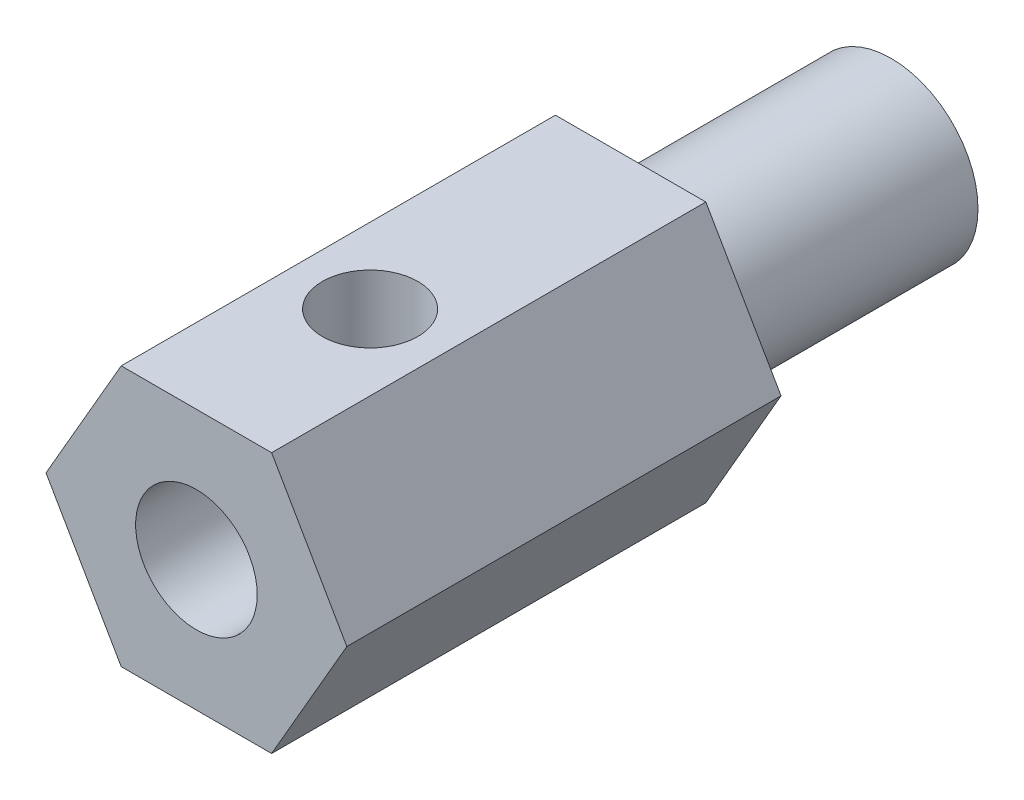
from build123d import *

# Parameters (mm, degrees)
BOSS_EXTRUDE1_DEPTH = 25.4
CUT_EXTRUDE1_DEPTH  = 8.89
SKETCH2_3_R         = 1.778
CUT_EXTRUDE2_DEPTH  = 2.54
SKETCH6_R           = 1.524
CUT_EXTRUDE3_DEPTH  = 16.51
SKETCH7_R           = 1.397
CUT_EXTRUDE4_DEPTH  = 3.81
SKETCH8_W           = 12.797374265
SKETCH8_H           = 12.133936035
CUT_EXTRUDE5_DEPTH  = 5.08
SKETCH9_R           = 5.447820482
SKETCH9_R_2         = 2.54
CUT_EXTRUDE6_DEPTH  = 7.62


with BuildPart() as part:
    # Sketch1 → Boss-Extrude1 (new body)
    with BuildSketch(Plane.XY):
        Polygon((2.199704526, 3.81), (-2.199704526, 3.81), (-4.399409051, 0), (-2.199704526, -3.81), (2.199704526, -3.81), (4.399409051, 0), align=None)
    extrude(amount=BOSS_EXTRUDE1_DEPTH)

    # Sketch2 → Cut-Extrude1 (cut)
    with BuildSketch(Plane.XY.offset(25.4)):
        with BuildLine():
            Line((1.459118912, 1.016), (-1.459118912, 1.016))
            ThreePointArc((-1.459118912, 1.016), (-0.532433364, -1.69640759), (1.778, 0))
            ThreePointArc((1.778, 0), (1.69640759, 0.532433364), (1.459118912, 1.016))
        make_face()
    extrude(amount=-CUT_EXTRUDE1_DEPTH, mode=Mode.SUBTRACT)

    # Sketch2_3 → Cut-Extrude2 (cut)
    with BuildSketch(Plane.XY.offset(25.4)):
        Circle(SKETCH2_3_R)
    extrude(amount=-CUT_EXTRUDE2_DEPTH, mode=Mode.SUBTRACT)

    # Sketch6 → Cut-Extrude3 (cut)
    with BuildSketch(Plane(origin=(0, 0, 0), x_dir=(-1, 0, 0), z_dir=(0, 0, -1))):
        Circle(SKETCH6_R)
    extrude(amount=-CUT_EXTRUDE3_DEPTH, mode=Mode.SUBTRACT)

    # Sketch7 → Cut-Extrude4 (cut)
    with BuildSketch(Plane(origin=(0, 3.81, 0), x_dir=(1, 0, 0), z_dir=(0, 1, 0))):
        with Locations((0, -20.32)):
            Circle(SKETCH7_R)
    extrude(amount=-CUT_EXTRUDE4_DEPTH, mode=Mode.SUBTRACT)

    # Sketch8 → Cut-Extrude5 (cut)
    with BuildSketch(Plane(origin=(0, 0, 0), x_dir=(-1, 0, 0), z_dir=(0, 0, -1))):
        with Locations((-0.392825268, 0.110181057)):
            Rectangle(SKETCH8_W, SKETCH8_H)
    extrude(amount=-CUT_EXTRUDE5_DEPTH, mode=Mode.SUBTRACT)

    # Sketch9 → Cut-Extrude6 (cut)
    with BuildSketch(Plane(origin=(0, 0, 5.08), x_dir=(-1, 0, 0), z_dir=(0, 0, -1))):
        Circle(SKETCH9_R)
        Circle(SKETCH9_R_2, mode=Mode.SUBTRACT)
    extrude(amount=-CUT_EXTRUDE6_DEPTH, mode=Mode.SUBTRACT)


solid = part.part
